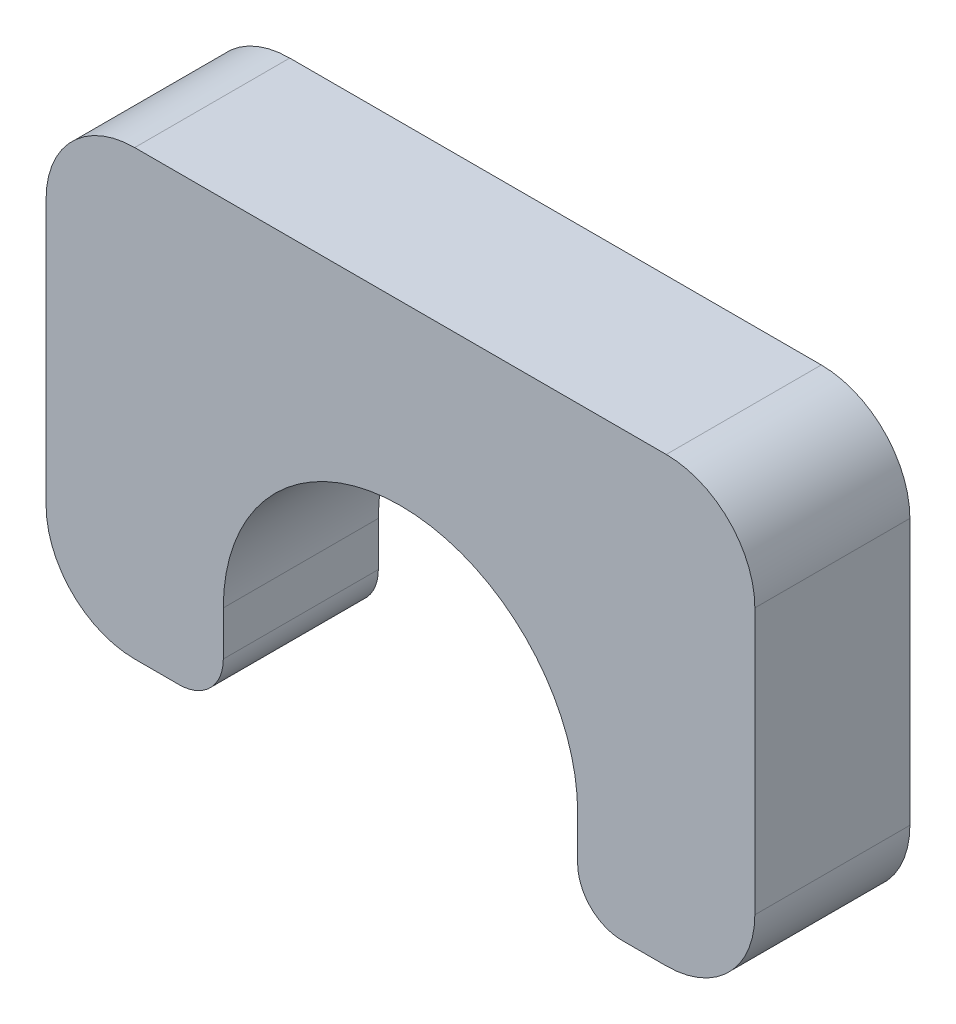
from build123d import *

# Parameters (mm, degrees)
BOSS_EXTRUDE1_DEPTH = 3.5
FILLET1_R           = 1


with BuildPart() as part:
    # Sketch1 → Boss-Extrude1 (new body)
    with BuildSketch(Plane.XY):
        with BuildLine():
            Line((-6, -5), (-4, -5))
            Line((-4, -5), (-4, -3))
            ThreePointArc((-4, -3), (0, 1), (4, -3))
            Line((4, -3), (4, -5))
            Line((4, -5), (6, -5))
            ThreePointArc((6, -5), (7.414213562, -4.414213562), (8, -3))
            Line((8, -3), (8, 3))
            ThreePointArc((8, 3), (7.414213562, 4.414213562), (6, 5))
            Line((6, 5), (-6, 5))
            ThreePointArc((-6, 5), (-7.414213562, 4.414213562), (-8, 3))
            Line((-8, 3), (-8, -3))
            ThreePointArc((-8, -3), (-7.414213562, -4.414213562), (-6, -5))
        make_face()
    extrude(amount=BOSS_EXTRUDE1_DEPTH)

    # Fillet1
    fillet1_edges = [part.edges().sort_by_distance(p)[0] for p in [
        (-4, -5, 1.75),
        (4, -5, 1.75),
    ]]
    fillet(fillet1_edges, radius=FILLET1_R)


solid = part.part
